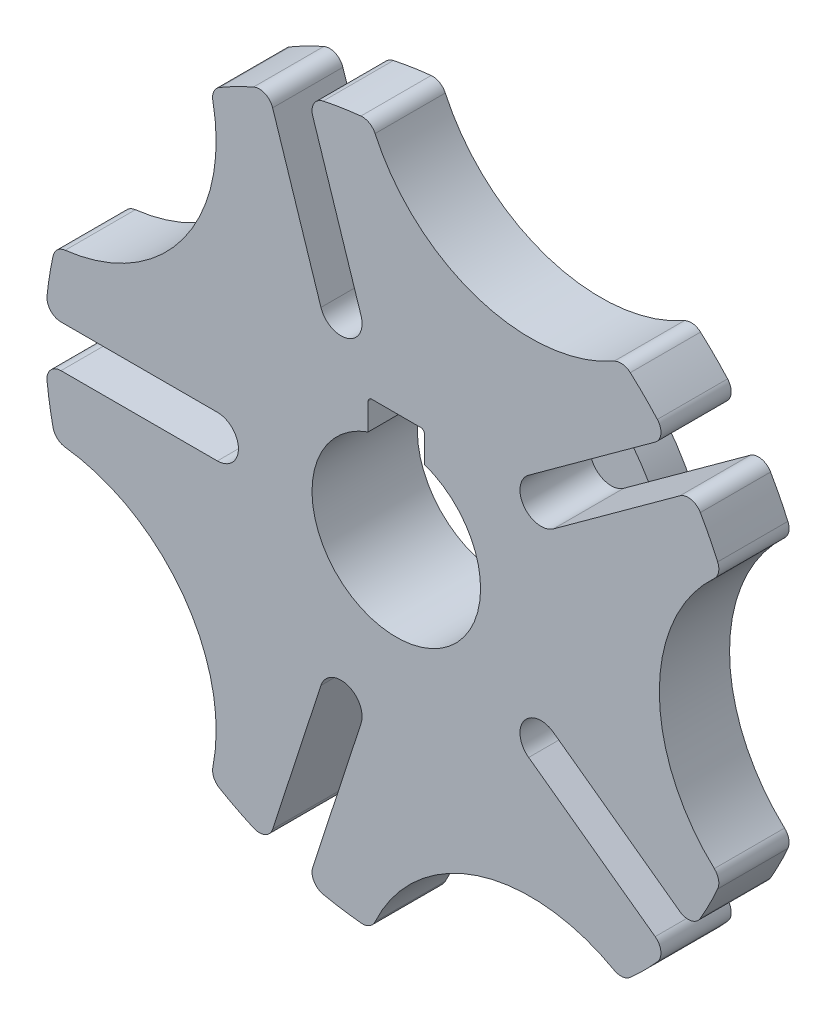
from build123d import *

# Parameters (mm, degrees)
BOSS_EXTRUDE1_DEPTH     = 5
SKETCH2_R               = 15
BOSS_EXTRUDE2_DEPTH     = 2.5
SKETCH3_R               = 6
SKETCH3_W               = 4
SKETCH3_H               = 3.6
CUT_EXTRUDE1_DEPTH      = 6
CUT_EXTRUDE1_DEPTH_BACK = 3.5
FILLET2_R               = 0.25
FILLET1_R               = 1


with BuildPart() as part:
    # Sketch1 → Boss-Extrude1 (new body)
    with BuildSketch(Plane.XY):
        with BuildLine():
            ThreePointArc((11.187046571, 6.27376313), (9.091843201, 6.605610744), (9.423690814, 8.700814114))
            Line((9.423690814, 8.700814114), (19.307308392, 15.881682614))
            ThreePointArc((19.307308392, 15.881682614), (17.777891388, 17.576876224), (16.100198302, 19.125470312))
            ThreePointArc((16.100198302, 19.125470312), (5.786474508, 17.808937333), (-1.783664646, 24.936289628))
            ThreePointArc((-1.783664646, 24.936289628), (-4.051187632, 24.669573948), (-6.284921782, 24.197102268))
            Line((-6.284921782, 24.197102268), (-2.5097158, 12.578212966))
            ThreePointArc((-2.5097158, 12.578212966), (-3.472775082, 10.6881027), (-5.362885348, 11.651161982))
            Line((-5.362885348, 11.651161982), (-9.138091331, 23.270051285))
            ThreePointArc((-9.138091331, 23.270051285), (-11.222932105, 22.339332912), (-13.214168279, 21.22229386))
            ThreePointArc((-13.214168279, 21.22229386), (-15.149186938, 11.006528575), (-24.267003431, 6.009371387))
            ThreePointArc((-24.267003431, 6.009371387), (-24.714044883, 3.770409198), (-24.954959427, 1.5))
            Line((-24.954959427, 1.5), (-12.738136237, 1.5))
            ThreePointArc((-12.738136237, 1.5), (-11.238136237, 0), (-12.738136237, -1.5))
            Line((-12.738136237, -1.5), (-24.954959427, -1.5))
            ThreePointArc((-24.954959427, -1.5), (-24.714044883, -3.770409198), (-24.267003431, -6.009371387))
            ThreePointArc((-24.267003431, -6.009371387), (-15.149186938, -11.006528575), (-13.214168279, -21.22229386))
            ThreePointArc((-13.214168279, -21.22229386), (-11.222932105, -22.339332912), (-9.138091331, -23.270051285))
            Line((-9.138091331, -23.270051285), (-5.362885348, -11.651161982))
            ThreePointArc((-5.362885348, -11.651161982), (-3.472775082, -10.6881027), (-2.5097158, -12.578212966))
            Line((-2.5097158, -12.578212966), (-6.284921782, -24.197102268))
            ThreePointArc((-6.284921782, -24.197102268), (-4.051187632, -24.669573948), (-1.783664646, -24.936289628))
            ThreePointArc((-1.783664646, -24.936289628), (5.786474508, -17.808937333), (16.100198302, -19.125470312))
            ThreePointArc((16.100198302, -19.125470312), (17.777891388, -17.576876224), (19.307308392, -15.881682614))
            Line((19.307308392, -15.881682614), (9.423690814, -8.700814114))
            ThreePointArc((9.423690814, -8.700814114), (9.091843201, -6.605610744), (11.187046571, -6.27376313))
            Line((11.187046571, -6.27376313), (21.070664149, -13.454631631))
            ThreePointArc((21.070664149, -13.454631631), (22.210273232, -11.47622599), (23.164638055, -9.402103157))
            ThreePointArc((23.164638055, -9.402103157), (18.725424859, 0), (23.164638055, 9.402103157))
            ThreePointArc((23.164638055, 9.402103157), (22.210273232, 11.47622599), (21.070664149, 13.454631631))
            Line((21.070664149, 13.454631631), (11.187046571, 6.27376313))
        make_face()
    extrude(amount=BOSS_EXTRUDE1_DEPTH)

    # Sketch2 → Boss-Extrude2 (add)
    with BuildSketch(Plane.XY):
        Circle(SKETCH2_R)
    extrude(amount=-BOSS_EXTRUDE2_DEPTH)

    # Sketch3 → Cut-Extrude1 (cut, two sides)
    with BuildSketch(Plane.XY) as cut_extrude1_sk:
        Circle(SKETCH3_R)
        with Locations((0, 6)):
            Rectangle(SKETCH3_W, SKETCH3_H)
    extrude(amount=CUT_EXTRUDE1_DEPTH, mode=Mode.SUBTRACT)
    extrude(cut_extrude1_sk.sketch, amount=-CUT_EXTRUDE1_DEPTH_BACK, mode=Mode.SUBTRACT)

    # Fillet2
    fillet2_edges = [part.edges().sort_by_distance(p)[0] for p in [
        (-2, 7.8, 1.25),
        (2, 7.8, 1.25),
    ]]
    fillet(fillet2_edges, radius=FILLET2_R)

    # Fillet1
    fillet1_edges = [part.edges().sort_by_distance(p)[0] for p in [
        (-6.284921782, 24.197102268, 2.5),
        (-1.783664646, 24.936289628, 2.5),
        (16.100198302, 19.125470312, 2.5),
        (19.307308392, 15.881682614, 2.5),
        (21.070664149, 13.454631631, 2.5),
        (23.164638055, 9.402103157, 2.5),
        (23.164638055, -9.402103157, 2.5),
        (21.070664149, -13.454631631, 2.5),
        (19.307308392, -15.881682614, 2.5),
        (16.100198302, -19.125470312, 2.5),
        (-1.783664646, -24.936289628, 2.5),
        (-6.284921782, -24.197102268, 2.5),
        (-9.138091331, -23.270051285, 2.5),
        (-13.214168279, -21.22229386, 2.5),
        (-24.267003431, -6.009371387, 2.5),
        (-24.954959427, -1.5, 2.5),
        (-24.954959427, 1.5, 2.5),
        (-24.267003431, 6.009371387, 2.5),
        (-13.214168279, 21.22229386, 2.5),
        (-9.138091331, 23.270051285, 2.5),
    ]]
    fillet(fillet1_edges, radius=FILLET1_R)


solid = part.part
